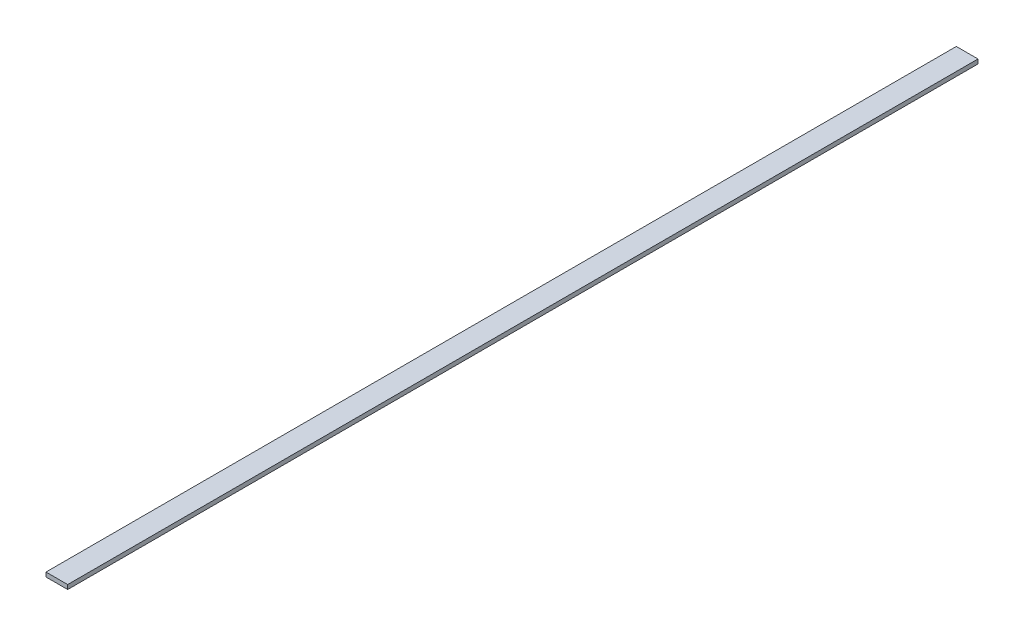
from build123d import *

# Parameters (mm, degrees)
ESQUISSE1_W      = 50
ESQUISSE1_H      = 2100
EXTRUSION1_DEPTH = 10


with BuildPart() as part:
    # Esquisse1 → Extrusion1 (new body)
    with BuildSketch(Plane(origin=(0, 0, 0), x_dir=(1, 0, 0), z_dir=(0, 1, 0))):
        with Locations((25, 1050)):
            Rectangle(ESQUISSE1_W, ESQUISSE1_H)
    extrude(amount=EXTRUSION1_DEPTH)


solid = part.part
